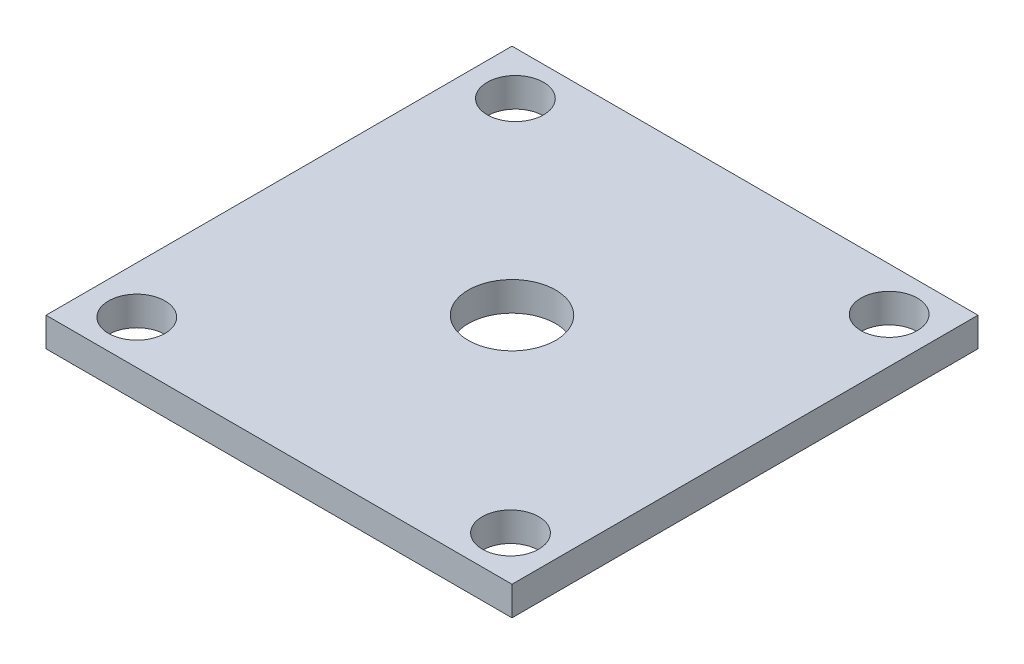
from build123d import *

# Parameters (mm, degrees)
SKETCH1_W                   = 101.6
SKETCH1_H                   = 101.6
BOSS_EXTRUDE1_DEPTH         = 6.35
F_9_16_12_TAPPED_HOLE1_D    = 12.30376
F_3_4_0_75_DIAMETER_HOLE1_D = 19.05


with BuildPart() as part:
    # Sketch1 → Boss-Extrude1 (new body)
    with BuildSketch(Plane(origin=(0, 0, 0), x_dir=(1, 0, 0), z_dir=(0, 1, 0))):
        with Locations((50.8, 50.8)):
            Rectangle(SKETCH1_W, SKETCH1_H)
    extrude(amount=BOSS_EXTRUDE1_DEPTH)

    # 9/16-12 Tapped Hole1 (through all)
    with Locations(Plane(origin=(0, 6.35, 0), x_dir=(1, 0, 0), z_dir=(0, 1, 0))):
        with Locations((10.266147992, 92.075), (91.751726771, 9.525), (91.751726771, 92.075), (10.266147992, 9.525)):
            Hole(F_9_16_12_TAPPED_HOLE1_D / 2)

    # 3/4 (0.75) Diameter Hole1 (through all)
    with Locations(Plane(origin=(0, 6.35, 0), x_dir=(1, 0, 0), z_dir=(0, 1, 0))):
        with Locations((50.8, 50.8)):
            Hole(F_3_4_0_75_DIAMETER_HOLE1_D / 2)


solid = part.part
